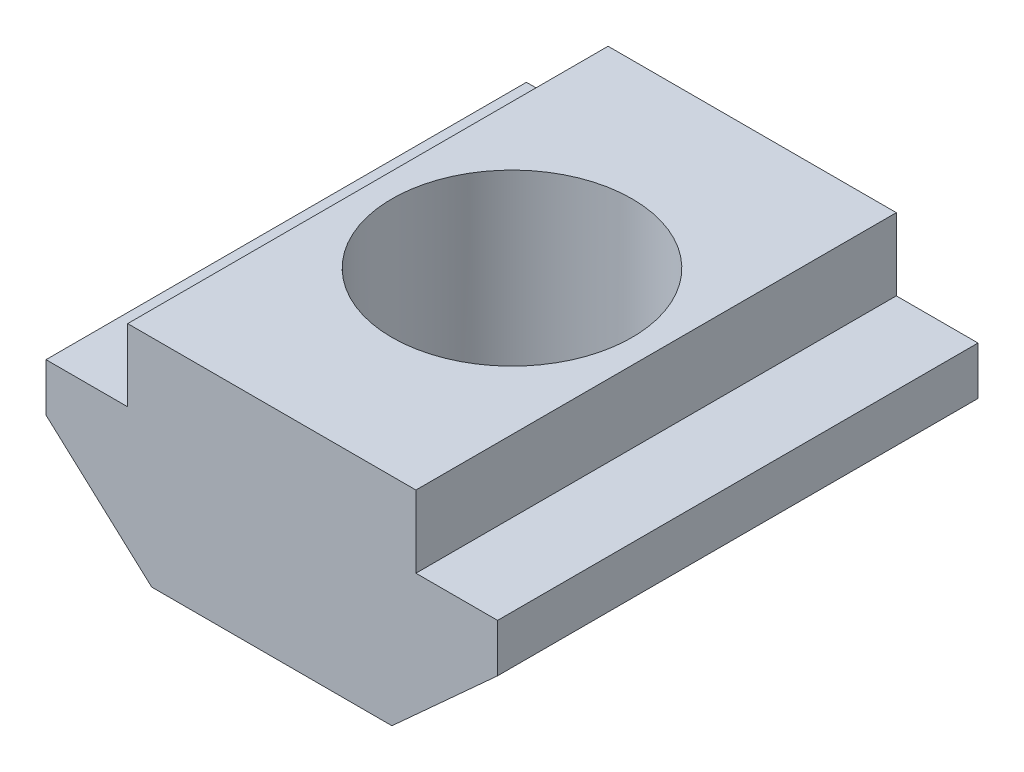
from build123d import *

# Parameters (mm, degrees)
EXTRUDE_1_DEPTH     = 5
SKETCH_2_R          = 2.5
CUT_EXTRUDE_1_DEPTH = 5.5


with BuildPart() as part:
    # Эскиз1 → Бобышка-Вытянуть1 (new body, symmetric)
    with BuildSketch(Plane.XY):
        Polygon((3, 0), (-3, 0), (-3, -1.5), (-4.7, -1.5), (-4.7, -2.5), (-2.5, -4.5), (2.5, -4.5), (4.7, -2.5), (4.7, -1.5), (3, -1.5), align=None)
    extrude(amount=EXTRUDE_1_DEPTH, both=True)

    # Эскиз2 → Вырез-Вытянуть1 (cut, through all)
    with BuildSketch(Plane(origin=(0, 0, 0), x_dir=(1, 0, 0), z_dir=(0, 1, 0))):
        with Locations(Location((0, 0, 0), (0, 0, 270))):  # turned: the seam where the file's is
            Circle(SKETCH_2_R)
    extrude(amount=-CUT_EXTRUDE_1_DEPTH, mode=Mode.SUBTRACT)


solid = part.part
